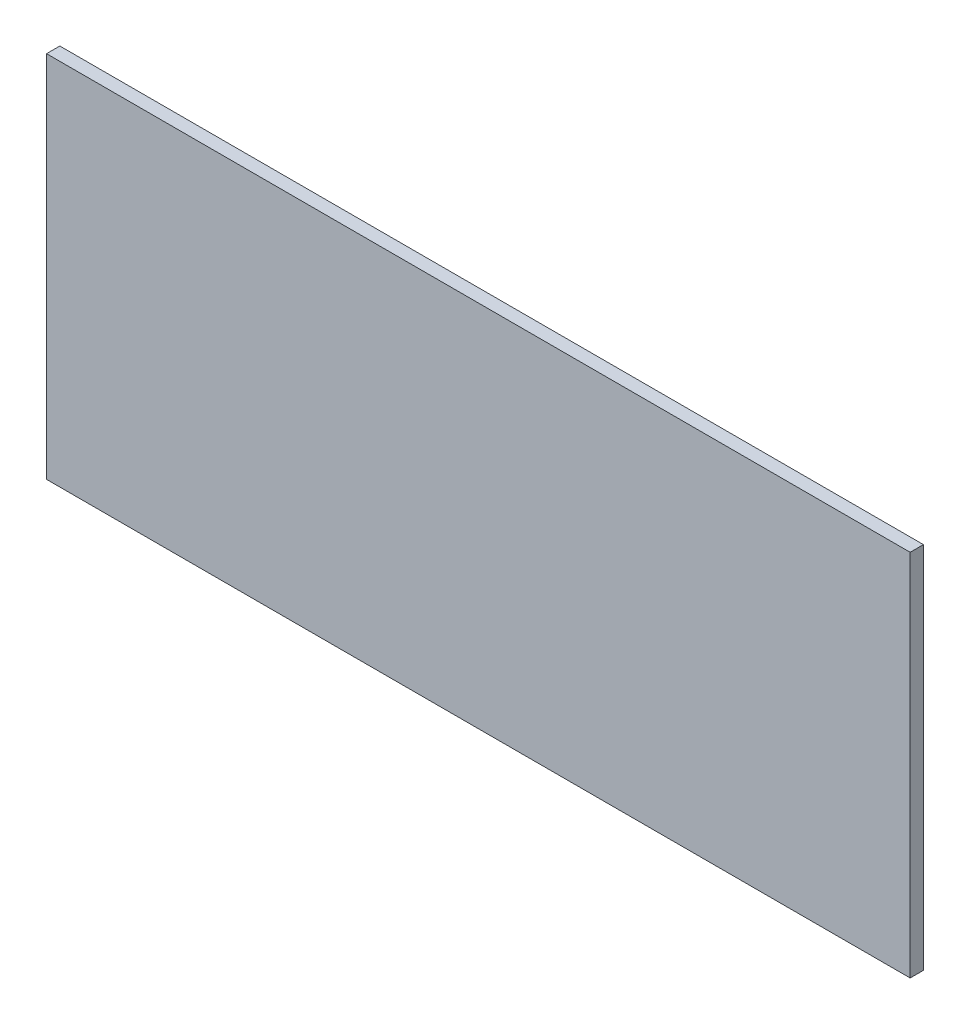
from build123d import *

# Parameters (mm, degrees)
CROQUIS1_W              = 1300
CROQUIS1_H              = 555
SALIENTE_EXTRUIR1_DEPTH = 20


with BuildPart() as part:
    # Croquis1 → Saliente-Extruir1 (new body)
    with BuildSketch(Plane.XY):
        with Locations((45.04491783, -67.205882353)):
            Rectangle(CROQUIS1_W, CROQUIS1_H)
    extrude(amount=SALIENTE_EXTRUIR1_DEPTH)


solid = part.part
